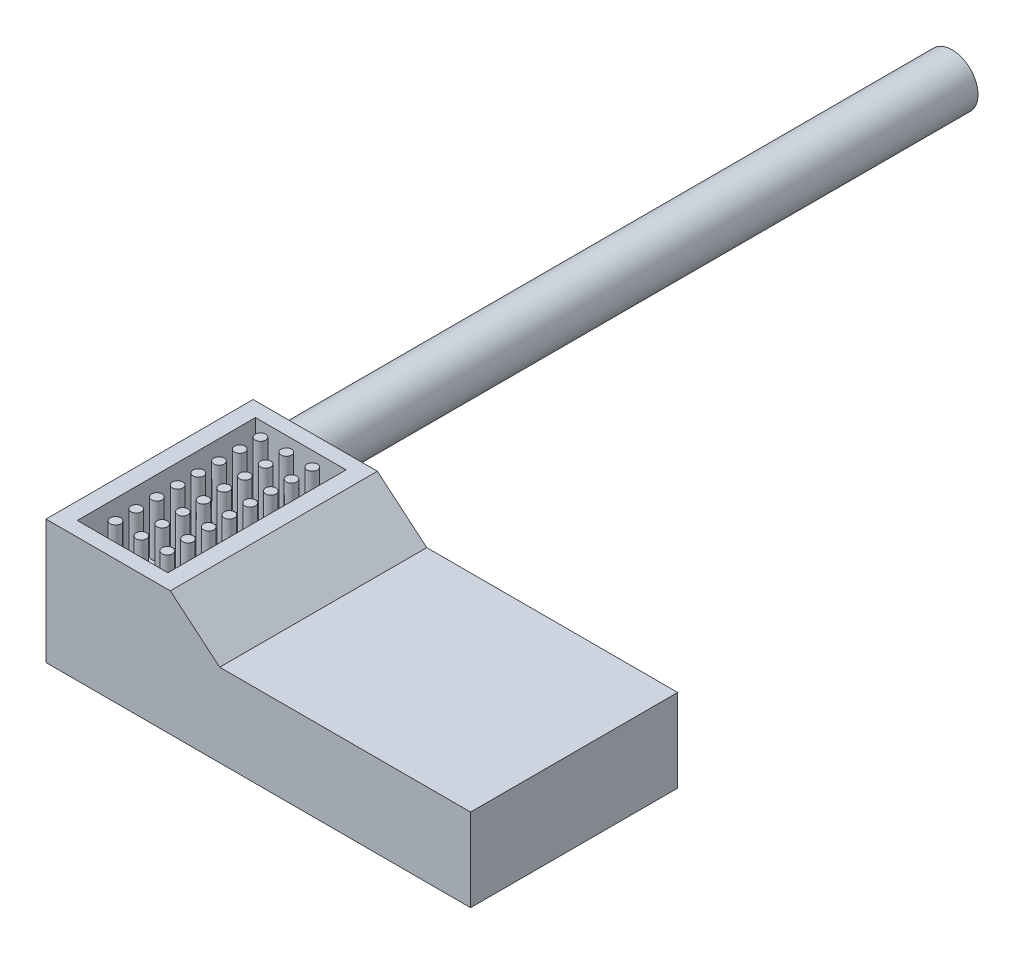
from build123d import *

# Parameters (mm, degrees)
BOSS_EXTRUDE1_DEPTH      = 10
BOSS_EXTRUDE1_DEPTH_BACK = 10
SKETCH4_W                = 8.748060076
SKETCH4_H                = 17.205061568
CUT_EXTRUDE1_DEPTH       = 5
SKETCH5_R                = 0.5
BOSS_EXTRUDE2_DEPTH      = 5
SKETCH6_R                = 2.5
BOSS_EXTRUDE3_DEPTH      = 80


with BuildPart() as part:
    # Sketch2 → Boss-Extrude1 (new, two sides: drawn at the far end of the back side and taken through both)
    with BuildSketch(Plane.XY.offset(-BOSS_EXTRUDE1_DEPTH_BACK)):
        Polygon((-3.652298851, 7.781609195), (-8.423850575, 11.781609195), (-20.423850575, 11.781609195), (-20.423850575, -0.218390805), (20.576149425, -0.218390805), (20.576149425, 7.781609195), align=None)
    extrude(amount=BOSS_EXTRUDE1_DEPTH + BOSS_EXTRUDE1_DEPTH_BACK)

    # Sketch4 → Cut-Extrude1 (cut)
    with BuildSketch(Plane(origin=(0, 11.781609195, 0), x_dir=(1, 0, 0), z_dir=(0, 1, 0))):
        with Locations((-14.423850575, 0)):
            Rectangle(SKETCH4_W, SKETCH4_H)
    extrude(amount=-CUT_EXTRUDE1_DEPTH, mode=Mode.SUBTRACT)

    # Sketch5 → Boss-Extrude2 (add)
    with BuildSketch(Plane(origin=(0, 6.781609195, 0), x_dir=(1, 0, 0), z_dir=(0, 1, 0))):
        with Locations((-16.923850575, 7.209208351)):
            Circle(SKETCH5_R)
        with Locations((-14.423850575, 7.209208351)):
            Circle(SKETCH5_R)
        with Locations((-11.923850575, 7.209208351)):
            Circle(SKETCH5_R)
        with Locations((-16.923850575, 5.209208351)):
            Circle(SKETCH5_R)
        with Locations((-11.923850575, 5.209208351)):
            Circle(SKETCH5_R)
        with Locations((-14.423850575, 5.209208351)):
            Circle(SKETCH5_R)
        with Locations((-16.923850575, 3.209208351)):
            Circle(SKETCH5_R)
        with Locations((-11.923850575, 3.209208351)):
            Circle(SKETCH5_R)
        with Locations((-14.423850575, 3.209208351)):
            Circle(SKETCH5_R)
        with Locations((-16.923850575, 1.209208351)):
            Circle(SKETCH5_R)
        with Locations((-11.923850575, 1.209208351)):
            Circle(SKETCH5_R)
        with Locations((-14.423850575, 1.209208351)):
            Circle(SKETCH5_R)
        with Locations((-16.923850575, -0.790791649)):
            Circle(SKETCH5_R)
        with Locations((-11.923850575, -0.790791649)):
            Circle(SKETCH5_R)
        with Locations((-14.423850575, -0.790791649)):
            Circle(SKETCH5_R)
        with Locations((-16.923850575, -2.790791649)):
            Circle(SKETCH5_R)
        with Locations((-11.923850575, -2.790791649)):
            Circle(SKETCH5_R)
        with Locations((-14.423850575, -2.790791649)):
            Circle(SKETCH5_R)
        with Locations((-16.923850575, -4.790791649)):
            Circle(SKETCH5_R)
        with Locations((-11.923850575, -4.790791649)):
            Circle(SKETCH5_R)
        with Locations((-14.423850575, -4.790791649)):
            Circle(SKETCH5_R)
        with Locations((-16.923850575, -6.790791649)):
            Circle(SKETCH5_R)
        with Locations((-11.923850575, -6.790791649)):
            Circle(SKETCH5_R)
        with Locations((-14.423850575, -6.790791649)):
            Circle(SKETCH5_R)
    extrude(amount=BOSS_EXTRUDE2_DEPTH)


with BuildPart() as body_2:
    # Sketch6 → Boss-Extrude3 (new body)
    with BuildSketch(Plane.XY):
        with Locations((-22.923850575, 2.281609195)):
            Circle(SKETCH6_R)
    extrude(amount=-BOSS_EXTRUDE3_DEPTH)


solid = Compound([part.part, body_2.part])
